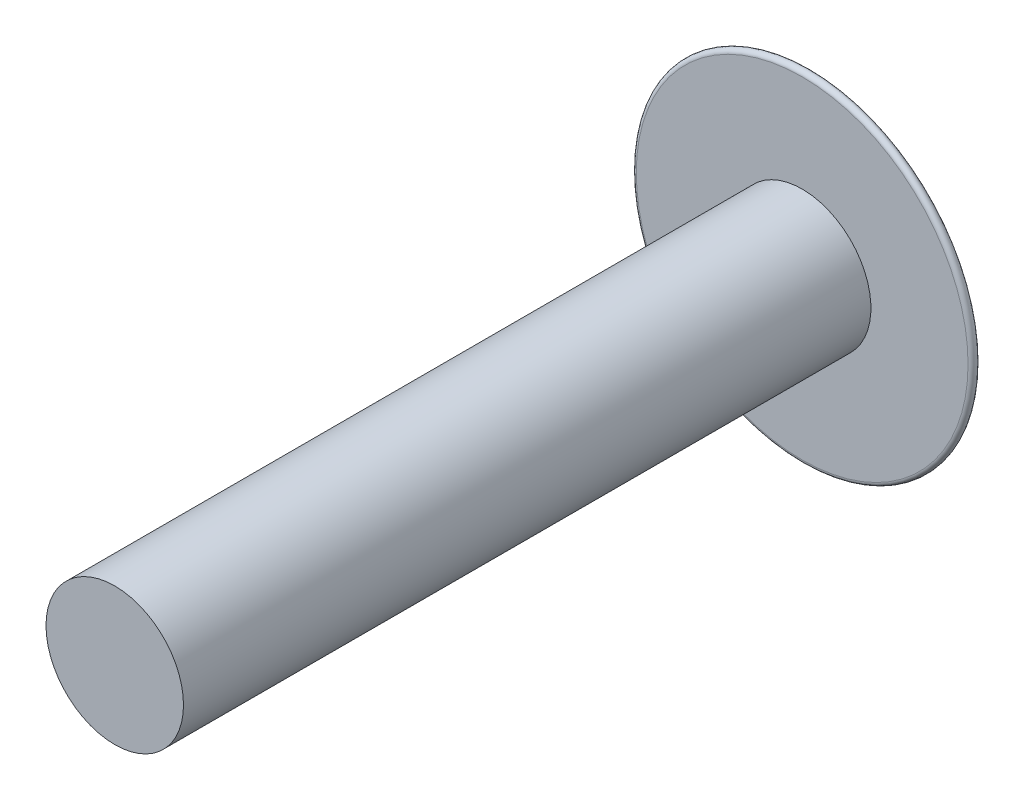
from build123d import *

# Parameters (mm, degrees)
SKETCH1_R               = 0.5
BOSS_EXTRUDE1_DEPTH     = 5
FILLET1_R               = 0.03
SKETCH3_W               = 0.2
SKETCH3_H               = 0.3
CUT_EXTRUDE1_DEPTH      = 2.236671107
CUT_EXTRUDE1_DEPTH_BACK = 2.236671107
SKETCH4_W               = 0.3
SKETCH4_H               = 0.199294318
CUT_EXTRUDE2_DEPTH      = 0.5


with BuildPart() as part:
    # Sketch1 → Boss-Extrude1 (new body)
    with BuildSketch(Plane.XY):
        Circle(SKETCH1_R)
    extrude(amount=BOSS_EXTRUDE1_DEPTH)

    # Sketch2 → Revolve1 (revolve)
    with BuildSketch(Plane(origin=(0, 0, 0), x_dir=(0, 0, -1), z_dir=(1, 0, 0))):
        with BuildLine():
            Line((0, 0), (0.4, 0))
            ThreePointArc((0.4, 0), (0.313905644, 0.685047891), (0, 1.3))
            Line((0, 1.3), (0, 0))
        make_face()
    revolve(axis=Axis((0, 0, 0), (0, 0, -1)))

    # Fillet1
    fillet1_edges = [part.edges().sort_by_distance(p)[0] for p in [
        (0, -1.3, 0),
    ]]
    fillet(fillet1_edges, radius=FILLET1_R)

    # Sketch3 → Cut-Extrude1 (cut, two sides)
    with BuildSketch(Plane(origin=(0, 0, 0), x_dir=(0, 0, -1), z_dir=(1, 0, 0))) as cut_extrude1_sk:
        with Locations((0.302347627, 0)):
            Rectangle(SKETCH3_W, SKETCH3_H)
    extrude(amount=CUT_EXTRUDE1_DEPTH, mode=Mode.SUBTRACT)
    extrude(cut_extrude1_sk.sketch, amount=-CUT_EXTRUDE1_DEPTH_BACK, mode=Mode.SUBTRACT)

    # Sketch4 → Cut-Extrude2 (cut, symmetric)
    with BuildSketch(Plane(origin=(0, 0, 0), x_dir=(1, 0, 0), z_dir=(0, 1, 0))):
        with Locations((0, 0.301994786)):
            Rectangle(SKETCH4_W, SKETCH4_H)
    extrude(amount=CUT_EXTRUDE2_DEPTH, both=True, mode=Mode.SUBTRACT)


solid = part.part
